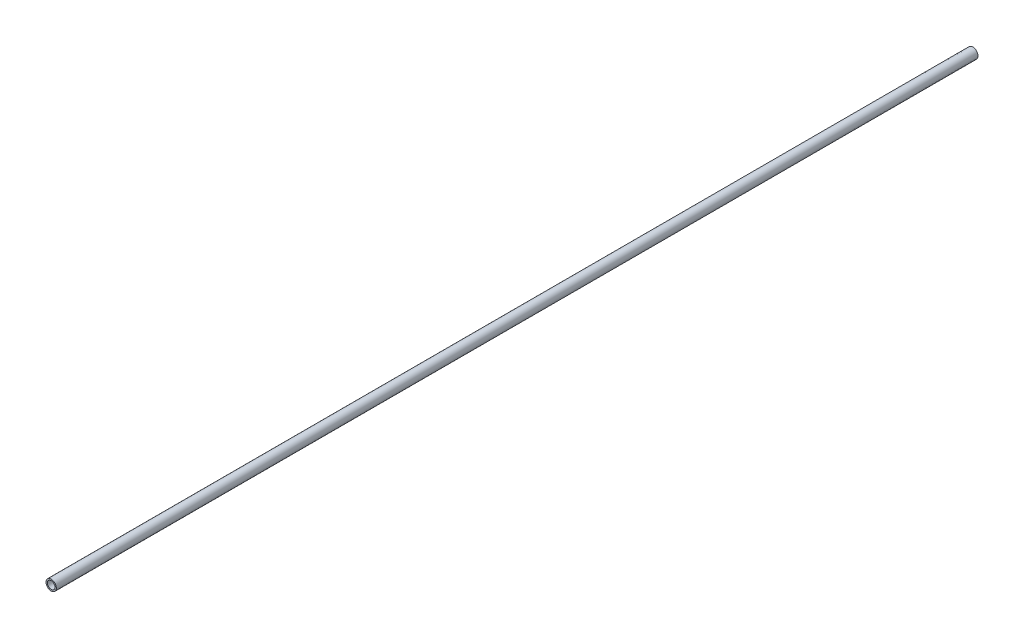
from build123d import *

# Parameters (mm, degrees)
SKETCH1_R           = 8.5725
SKETCH1_R_2         = 6.2611
EXTRUDE_THIN1_DEPTH = 762


with BuildPart() as part:
    # Sketch1 → Extrude-Thin1 (new body, symmetric)
    with BuildSketch(Plane.XY):
        Circle(SKETCH1_R)
        Circle(SKETCH1_R_2, mode=Mode.SUBTRACT)
    extrude(amount=EXTRUDE_THIN1_DEPTH, both=True)


solid = part.part
